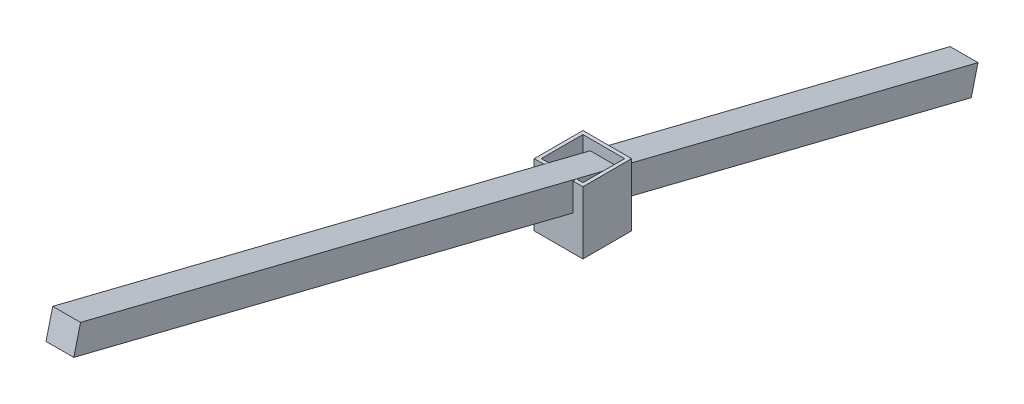
from build123d import *

# Parameters (mm, degrees)
SKETCH1_W                = 35
SKETCH1_H                = 35
SKETCH1_W_2              = 30
SKETCH1_H_2              = 30
BOSS_EXTRUDE1_DEPTH      = 45
SKETCH5_W                = 20
SKETCH5_H                = 20
BOSS_EXTRUDE3_DEPTH      = 302.5
BOSS_EXTRUDE3_DEPTH_BACK = 362.5


with BuildPart() as part:
    # Sketch1 → Boss-Extrude1 (new body)
    with BuildSketch(Plane(origin=(0, 0, 0), x_dir=(1, 0, 0), z_dir=(0, 1, 0))):
        Rectangle(SKETCH1_W, SKETCH1_H)
        Rectangle(SKETCH1_W_2, SKETCH1_H_2, mode=Mode.SUBTRACT)
    extrude(amount=-BOSS_EXTRUDE1_DEPTH)

    # Sketch5 → Boss-Extrude3 (add, two sides)
    with BuildSketch(Plane(origin=(0, 4.694715628, 18.829475929), x_dir=(1, 0, 0), z_dir=(0, -0.241921896, -0.970295726))) as boss_extrude3_sk:
        with Locations((0.25, 13.628828434)):
            Rectangle(SKETCH5_W, SKETCH5_H)
    extrude(amount=BOSS_EXTRUDE3_DEPTH)
    extrude(boss_extrude3_sk.sketch, amount=-BOSS_EXTRUDE3_DEPTH_BACK)


solid = part.part
